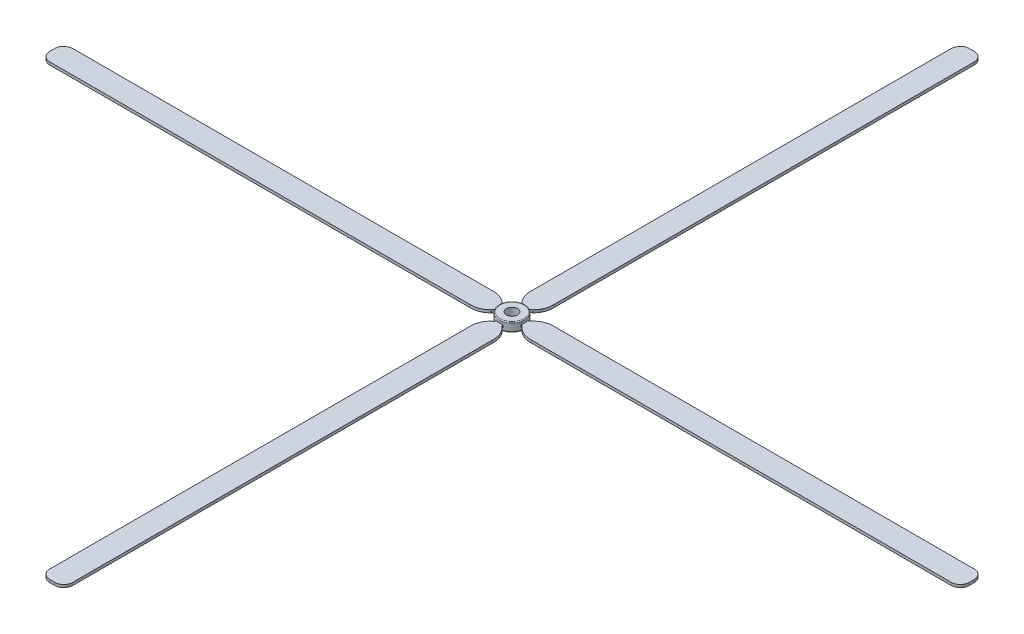
from build123d import *

# Parameters (mm, degrees)
IZIM2_R                          = 1
Y_KSEKLIK_EKSTR_ZYON1_DEPTH      = 1
Y_KSEKLIK_EKSTR_ZYON1_DEPTH_BACK = 1
RADYUS1_R                        = 0.2
RADYUS2_R                        = 0.2
Y_KSEKLIK_EKSTR_ZYON3_DEPTH      = 0.3
Y_KSEKLIK_EKSTR_ZYON3_DEPTH_BACK = 0.3
IZIM7_R                          = 1.22
KES_EKSTR_ZYON1_DEPTH            = 10.3
KES_EKSTR_ZYON1_DEPTH_BACK       = 10.3
Y_KSEKLIK_EKSTR_ZYON4_DEPTH      = 0.3
Y_KSEKLIK_EKSTR_ZYON4_DEPTH_BACK = 0.3


with BuildPart() as part:
    # izim2 → Y_kseklik-Ekstr_zyon1 (new body, two sides)
    with BuildSketch(Plane(origin=(0, 0, 0), x_dir=(1, 0, 0), z_dir=(0, 1, 0))) as y_kseklik_ekstr_zyon1_sk:
        with BuildLine():
            ThreePointArc((1.495287, 2.381188), (0, 2.81175), (-1.495287, 2.381188))
            ThreePointArc((-1.495287, 2.381188), (-1.988208, 1.988208), (-2.381188, 1.495287))
            ThreePointArc((-2.381188, 1.495287), (-2.81175, 0), (-2.381188, -1.495287))
            ThreePointArc((-2.381188, -1.495287), (-1.988208, -1.988208), (-1.495287, -2.381188))
            ThreePointArc((-1.495287, -2.381188), (0, -2.81175), (1.495287, -2.381188))
            ThreePointArc((1.495287, -2.381188), (1.988208, -1.988208), (2.381188, -1.495287))
            ThreePointArc((2.381188, -1.495287), (2.701966, -0.778021), (2.81175, 0))
            ThreePointArc((2.81175, 0), (2.701966, 0.778021), (2.381188, 1.495287))
            ThreePointArc((2.381188, 1.495287), (1.988208, 1.988208), (1.495287, 2.381188))
        make_face()
        Circle(IZIM2_R, mode=Mode.SUBTRACT)
    extrude(amount=Y_KSEKLIK_EKSTR_ZYON1_DEPTH)
    extrude(y_kseklik_ekstr_zyon1_sk.sketch, amount=-Y_KSEKLIK_EKSTR_ZYON1_DEPTH_BACK)

    # Radyus1
    radyus1_edges = [part.edges().sort_by_distance(p)[0] for p in [
        (1.495287, 1, -2.381188),
    ]]
    fillet(radyus1_edges, radius=RADYUS1_R)

    # Radyus2
    radyus2_edges = [part.edges().sort_by_distance(p)[0] for p in [
        (1.495287, -1, -2.381188),
    ]]
    fillet(radyus2_edges, radius=RADYUS2_R)

    # izim4 → Y_kseklik-Ekstr_zyon3 (add, two sides)
    with BuildSketch(Plane(origin=(0, 0, 0), x_dir=(1, 0, 0), z_dir=(0, 1, 0))) as y_kseklik_ekstr_zyon3_sk:
        with BuildLine():
            ThreePointArc((1.217938, 3.369108), (0, 3.827555), (-1.217938, 3.369108))
            add(Edge.make_bspline(
                [(-0.747231, 2.71516), (-0.801692, 3.162131), (-1.217938, 3.369108)],
                knots=[0, 0, 0, 1, 1, 1], degree=2))
            ThreePointArc((-0.747231, 2.71516), (-0.018505, 2.811234), (0.710221, 2.71516))
            add(Edge.make_bspline(
                [(0.710221, 2.71516), (0.763603, 3.182238), (1.217938, 3.369108)],
                knots=[0, 0, 0, 1, 1, 1], degree=2))
        make_face()
        with BuildLine():
            ThreePointArc((3.369108, -1.217938), (3.827555, 0), (3.369108, 1.217938))
            add(Edge.make_bspline(
                [(2.71516, 0.747231), (3.162131, 0.801692), (3.369108, 1.217938)],
                knots=[0, 0, 0, 1, 1, 1], degree=2))
            ThreePointArc((2.71516, 0.747231), (2.811234, 0.018505), (2.71516, -0.710221))
            add(Edge.make_bspline(
                [(2.71516, -0.710221), (3.182238, -0.763603), (3.369108, -1.217938)],
                knots=[0, 0, 0, 1, 1, 1], degree=2))
        make_face()
        with BuildLine():
            ThreePointArc((-1.217938, -3.369108), (0, -3.827555), (1.217938, -3.369108))
            add(Edge.make_bspline(
                [(0.747231, -2.71516), (0.801692, -3.162131), (1.217938, -3.369108)],
                knots=[0, 0, 0, 1, 1, 1], degree=2))
            ThreePointArc((0.747231, -2.71516), (0.018505, -2.811234), (-0.710221, -2.71516))
            add(Edge.make_bspline(
                [(-0.710221, -2.71516), (-0.763603, -3.182238), (-1.217938, -3.369108)],
                knots=[0, 0, 0, 1, 1, 1], degree=2))
        make_face()
        with BuildLine():
            ThreePointArc((-3.369108, 1.217938), (-3.827555, 0), (-3.369108, -1.217938))
            add(Edge.make_bspline(
                [(-2.71516, -0.747231), (-3.162131, -0.801692), (-3.369108, -1.217938)],
                knots=[0, 0, 0, 1, 1, 1], degree=2))
            ThreePointArc((-2.71516, -0.747231), (-2.811234, -0.018505), (-2.71516, 0.710221))
            add(Edge.make_bspline(
                [(-2.71516, 0.710221), (-3.182238, 0.763603), (-3.369108, 1.217938)],
                knots=[0, 0, 0, 1, 1, 1], degree=2))
        make_face()
    extrude(amount=Y_KSEKLIK_EKSTR_ZYON3_DEPTH)
    extrude(y_kseklik_ekstr_zyon3_sk.sketch, amount=-Y_KSEKLIK_EKSTR_ZYON3_DEPTH_BACK)

    # izim7 → Kes-Ekstr_zyon1 (cut, two sides)
    with BuildSketch(Plane(origin=(0, 0, 0), x_dir=(1, 0, 0), z_dir=(0, 1, 0))) as kes_ekstr_zyon1_sk:
        Circle(IZIM7_R)
    extrude(amount=KES_EKSTR_ZYON1_DEPTH, mode=Mode.SUBTRACT)
    extrude(kes_ekstr_zyon1_sk.sketch, amount=-KES_EKSTR_ZYON1_DEPTH_BACK, mode=Mode.SUBTRACT)

    # izim5 → Y_kseklik-Ekstr_zyon4 (add, two sides)
    with BuildSketch(Plane(origin=(0, 0, 0), x_dir=(1, 0, 0), z_dir=(0, 1, 0))) as y_kseklik_ekstr_zyon4_sk:
        with BuildLine():
            Line((3.369108, 1.217938), (3.369108, -1.217938))
            add(Edge.make_bspline(
                [(3.369108, -1.217938), (4.826883, -2.602487), (6.797528, -2.54257)],
                knots=[0, 0, 0, 1, 1, 1], degree=2))
            Line((6.797528, -2.54257), (99.369108, -2.54257))
            ThreePointArc((99.369108, -2.54257), (100.783321, -1.956783), (101.369108, -0.54257))
            Line((101.369108, -0.54257), (101.369108, 0.54257))
            ThreePointArc((101.369108, 0.54257), (100.783321, 1.956783), (99.369108, 2.54257))
            Line((99.369108, 2.54257), (6.797528, 2.54257))
            add(Edge.make_bspline(
                [(3.369108, 1.217938), (4.826883, 2.602487), (6.797528, 2.54257)],
                knots=[0, 0, 0, 1, 1, 1], degree=2))
        make_face()
        with BuildLine():
            ThreePointArc((0.54257, -101.369108), (1.956783, -100.783321), (2.54257, -99.369108))
            Line((2.54257, -99.369108), (2.54257, -6.797528))
            add(Edge.make_bspline(
                [(1.217938, -3.369108), (2.602487, -4.826883), (2.54257, -6.797528)],
                knots=[0, 0, 0, 1, 1, 1], degree=2))
            Line((1.217938, -3.369108), (-1.217938, -3.369108))
            add(Edge.make_bspline(
                [(-1.217938, -3.369108), (-2.602487, -4.826883), (-2.54257, -6.797528)],
                knots=[0, 0, 0, 1, 1, 1], degree=2))
            Line((-2.54257, -6.797528), (-2.54257, -99.369108))
            ThreePointArc((-2.54257, -99.369108), (-1.956783, -100.783321), (-0.54257, -101.369108))
            Line((-0.54257, -101.369108), (0.54257, -101.369108))
        make_face()
        with BuildLine():
            ThreePointArc((-101.369108, -0.54257), (-100.783321, -1.956783), (-99.369108, -2.54257))
            Line((-99.369108, -2.54257), (-6.797528, -2.54257))
            add(Edge.make_bspline(
                [(-3.369108, -1.217938), (-4.826883, -2.602487), (-6.797528, -2.54257)],
                knots=[0, 0, 0, 1, 1, 1], degree=2))
            Line((-3.369108, -1.217938), (-3.369108, 1.217938))
            add(Edge.make_bspline(
                [(-3.369108, 1.217938), (-4.826883, 2.602487), (-6.797528, 2.54257)],
                knots=[0, 0, 0, 1, 1, 1], degree=2))
            Line((-6.797528, 2.54257), (-99.369108, 2.54257))
            ThreePointArc((-99.369108, 2.54257), (-100.783321, 1.956783), (-101.369108, 0.54257))
            Line((-101.369108, 0.54257), (-101.369108, -0.54257))
        make_face()
        with BuildLine():
            ThreePointArc((-0.54257, 101.369108), (-1.956783, 100.783321), (-2.54257, 99.369108))
            Line((-2.54257, 99.369108), (-2.54257, 6.797528))
            add(Edge.make_bspline(
                [(-1.217938, 3.369108), (-2.602487, 4.826883), (-2.54257, 6.797528)],
                knots=[0, 0, 0, 1, 1, 1], degree=2))
            Line((-1.217938, 3.369108), (1.217938, 3.369108))
            add(Edge.make_bspline(
                [(1.217938, 3.369108), (2.602487, 4.826883), (2.54257, 6.797528)],
                knots=[0, 0, 0, 1, 1, 1], degree=2))
            Line((2.54257, 6.797528), (2.54257, 99.369108))
            ThreePointArc((2.54257, 99.369108), (1.956783, 100.783321), (0.54257, 101.369108))
            Line((0.54257, 101.369108), (-0.54257, 101.369108))
        make_face()
    extrude(amount=Y_KSEKLIK_EKSTR_ZYON4_DEPTH)
    extrude(y_kseklik_ekstr_zyon4_sk.sketch, amount=-Y_KSEKLIK_EKSTR_ZYON4_DEPTH_BACK)


solid = part.part
